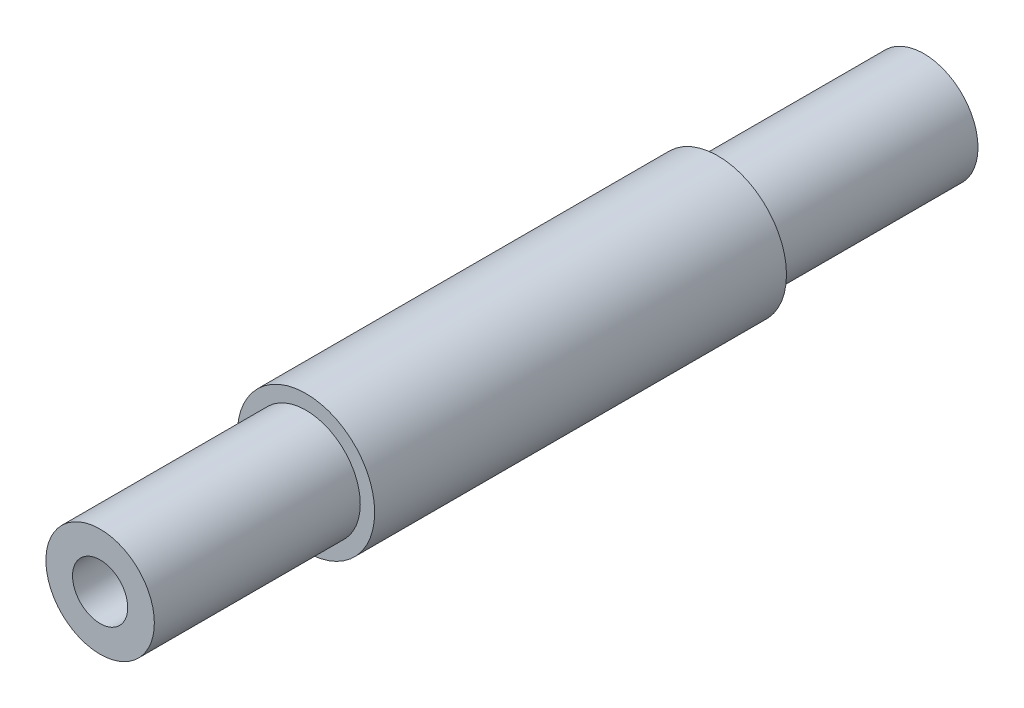
from build123d import *

# Parameters (mm, degrees)
SKETCH1_R                  = 6.35
SKETCH1_R_2                = 5.0165
BOSS_EXTRUDE1_DEPTH        = 19.05
SKETCH1_4_R                = 5.0165
BOSS_EXTRUDE2_DEPTH        = 38.1
F_7_0_201_DIAMETER_HOLE1_D = 5.1054


with BuildPart() as part:
    # Sketch1 → Boss-Extrude1 (new, symmetric)
    with BuildSketch(Plane.XY):
        Circle(SKETCH1_R)
        Circle(SKETCH1_R_2, mode=Mode.SUBTRACT)
    extrude(amount=BOSS_EXTRUDE1_DEPTH, both=True)

    # Sketch1_4 → Boss-Extrude2 (add, symmetric)
    with BuildSketch(Plane.XY):
        Circle(SKETCH1_4_R)
    extrude(amount=BOSS_EXTRUDE2_DEPTH, both=True)

    # 7 _0.201_ Diameter Hole1 (through all)
    with Locations(Plane(origin=(0, 0, -38.1), x_dir=(-1, 0, 0), z_dir=(0, 0, -1))):
        with Locations((0, 0)):
            Hole(F_7_0_201_DIAMETER_HOLE1_D / 2)


solid = part.part
